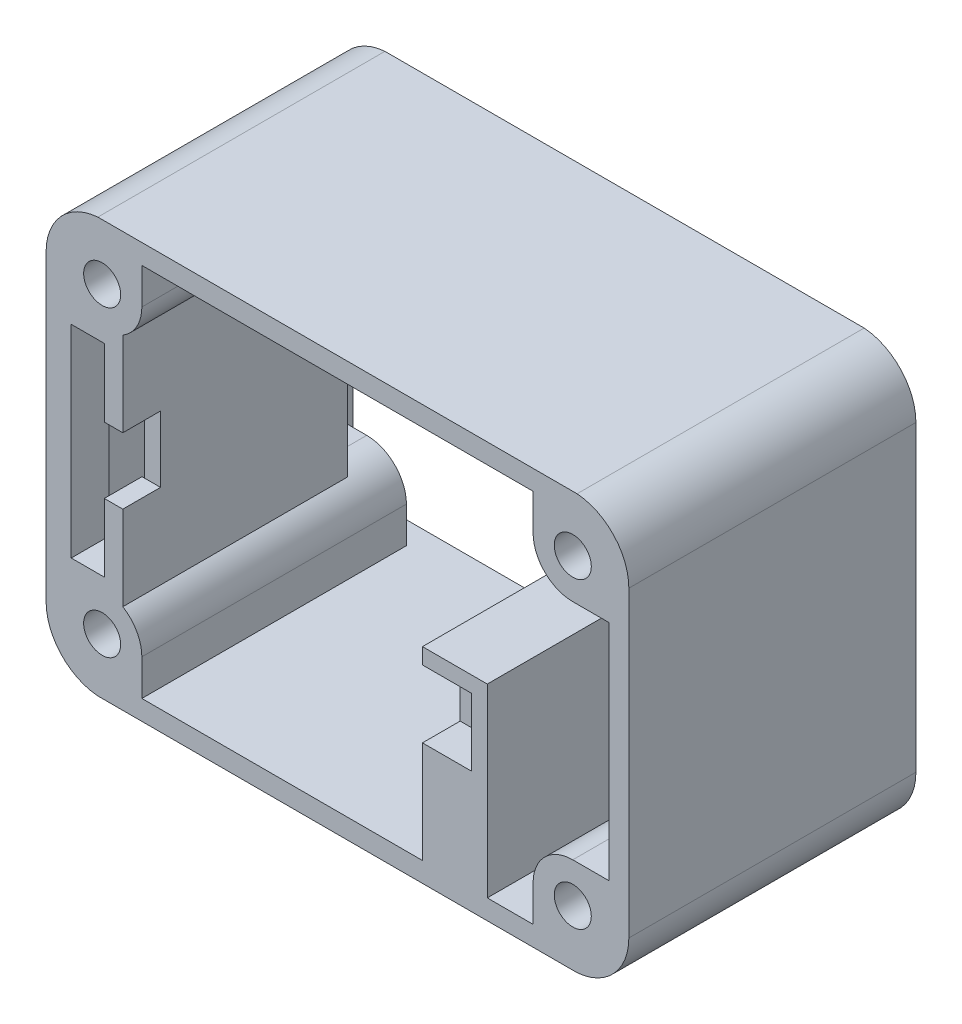
from build123d import *

# Parameters (mm, degrees)
SKETCH1_W           = 44.05
SKETCH1_H           = 31.35
SKETCH1_R           = 1.4
BOSS_EXTRUDE1_DEPTH = 20
SKETCH2_W           = 44.05
SKETCH2_H           = 31.35
BOSS_EXTRUDE2_DEPTH = 1.7
SKETCH3_W           = 2.9
SKETCH3_H           = 15.7
SKETCH3_W_2         = 4.9
SKETCH3_H_2         = 14
SKETCH3_H_3         = 5.5
BOSS_EXTRUDE3_DEPTH = 14.15
SKETCH4_W           = 4.9
SKETCH4_H           = 14
SKETCH4_W_2         = 2.5
SKETCH4_H_2         = 5.1
SKETCH4_H_3         = 15.3
BOSS_EXTRUDE4_DEPTH = 2.85
SKETCH5_W           = 1.4
SKETCH5_H           = 5
SKETCH5_W_2         = 1.2
SKETCH5_H_2         = 5.1
CUT_EXTRUDE1_DEPTH  = 2.85
CUT_EXTRUDE2_REACH  = 23.7


with BuildPart() as part:
    # Sketch1 → Boss-Extrude1 (new body)
    with BuildSketch(Plane.XY):
        Rectangle(SKETCH1_W, SKETCH1_H)
        with Locations((-17.7875, -11.45)):
            Circle(SKETCH1_R, mode=Mode.SUBTRACT)
        with Locations((17.7875, -11.45)):
            Circle(SKETCH1_R, mode=Mode.SUBTRACT)
        with BuildLine():
            Line((-17.7875, -8.45), (-20.525, -8.45))
            Line((-20.525, -8.45), (-20.525, 8.45))
            Line((-20.525, 8.45), (-17.7875, 8.45))
            ThreePointArc((-17.7875, 8.45), (-15.666179656, 9.328679656), (-14.7875, 11.45))
            Line((-14.7875, 11.45), (-14.7875, 14.175))
            Line((-14.7875, 14.175), (14.7875, 14.175))
            Line((14.7875, 14.175), (14.7875, 11.45))
            ThreePointArc((14.7875, 11.45), (15.666179656, 9.328679656), (17.7875, 8.45))
            Line((17.7875, 8.45), (20.525, 8.45))
            Line((20.525, 8.45), (20.525, -8.45))
            Line((20.525, -8.45), (17.7875, -8.45))
            ThreePointArc((17.7875, -8.45), (15.666179656, -9.328679656), (14.7875, -11.45))
            Line((14.7875, -11.45), (14.7875, -14.175))
            Line((14.7875, -14.175), (-14.7875, -14.175))
            Line((-14.7875, -14.175), (-14.7875, -11.45))
            ThreePointArc((-14.7875, -11.45), (-15.666179656, -9.328679656), (-17.7875, -8.45))
        make_face(mode=Mode.SUBTRACT)
        with Locations((-17.7875, 11.45)):
            Circle(SKETCH1_R, mode=Mode.SUBTRACT)
        with Locations((17.7875, 11.45)):
            Circle(SKETCH1_R, mode=Mode.SUBTRACT)
    extrude(amount=BOSS_EXTRUDE1_DEPTH)

    # Sketch2 → Boss-Extrude2 (add)
    with BuildSketch(Plane(origin=(0, 0, 0), x_dir=(-1, 0, 0), z_dir=(0, 0, -1))):
        Rectangle(SKETCH2_W, SKETCH2_H)
        Polygon((-20.525, 8.45), (-20.525, 14.175), (-14.7875, 14.175), (-2, 14.175), (-2, 14.925), (2, 14.925), (2, 14.175), (14.7875, 14.175), (20.525, 14.175), (20.525, 8.45), (20.525, 2), (21.275, 2), (21.275, -2), (20.525, -2), (20.525, -8.45), (20.525, -14.175), (14.7875, -14.175), (2, -14.175), (2, -14.925), (-2, -14.925), (-2, -14.175), (-14.7875, -14.175), (-20.525, -14.175), (-20.525, -8.45), (-20.525, -2), (-21.275, -2), (-21.275, 2), (-20.525, 2), align=None, mode=Mode.SUBTRACT)
    extrude(amount=BOSS_EXTRUDE2_DEPTH)

    # Sketch3 → Boss-Extrude3 (add)
    with BuildSketch(Plane(origin=(0, 0, 3), x_dir=(-1, 0, 0), z_dir=(0, 0, -1))):
        with BuildLine():
            ThreePointArc((16.225, -8.889024844), (16.975996909, -8.561840944), (17.7875, -8.45))
            Line((17.7875, -8.45), (20.525, -8.45))
            Line((20.525, -8.45), (20.525, 8.45))
            Line((20.525, 8.45), (17.7875, 8.45))
            ThreePointArc((17.7875, 8.45), (16.975996909, 8.561840944), (16.225, 8.889024844))
            Line((16.225, 8.889024844), (16.225, -8.889024844))
        make_face()
        with Locations((18.875, 0)):
            Rectangle(SKETCH3_W, SKETCH3_H, mode=Mode.SUBTRACT)
        with Locations((-8.875, -7.175)):
            Rectangle(SKETCH3_W_2, SKETCH3_H_2)
        with Locations((-8.875, -3.925)):
            Rectangle(SKETCH3_W, SKETCH3_H_3, mode=Mode.SUBTRACT)
    extrude(amount=-BOSS_EXTRUDE3_DEPTH)

    # Sketch4 → Boss-Extrude4 (add)
    with BuildSketch(Plane.XY.offset(17.15)):
        with Locations((8.875, -7.175)):
            Rectangle(SKETCH4_W, SKETCH4_H)
        with Locations((8.875, -3.925)):
            Rectangle(SKETCH4_W_2, SKETCH4_H_2, mode=Mode.SUBTRACT)
        with BuildLine():
            Line((-20.525, -8.45), (-17.7875, -8.45))
            ThreePointArc((-17.7875, -8.45), (-16.975996909, -8.561840944), (-16.225, -8.889024844))
            Line((-16.225, -8.889024844), (-16.225, 8.889024844))
            ThreePointArc((-16.225, 8.889024844), (-16.975996909, 8.561840944), (-17.7875, 8.45))
            Line((-17.7875, 8.45), (-20.525, 8.45))
            Line((-20.525, 8.45), (-20.525, -8.45))
        make_face()
        with Locations((-18.875, 0)):
            Rectangle(SKETCH4_W_2, SKETCH4_H_3, mode=Mode.SUBTRACT)
    extrude(amount=BOSS_EXTRUDE4_DEPTH)

    # Sketch5 → Cut-Extrude1 (cut)
    with BuildSketch(Plane.XY.offset(20)):
        with Locations((-16.925, 0)):
            Rectangle(SKETCH5_W, SKETCH5_H)
        with Locations((7.025, -3.925)):
            Rectangle(SKETCH5_W_2, SKETCH5_H_2)
    extrude(amount=-CUT_EXTRUDE1_DEPTH, mode=Mode.SUBTRACT)

    # Sketch6 → Cut-Extrude2 (cut, up to next)
    with BuildSketch(Plane(origin=(0, 0, -1.7), x_dir=(-1, 0, 0), z_dir=(0, 0, -1)), mode=Mode.PRIVATE) as cut_extrude2_sk1:
        with BuildLine():
            Line((-18.112740296, 15.675), (-22.025, 15.675))
            Line((-22.025, 15.675), (-22.025, 11.45))
            ThreePointArc((-22.025, 11.45), (-20.896729165, 14.329079757), (-18.112740296, 15.675))
        make_face()
    cut_extrude2_tool1 = extrude(cut_extrude2_sk1.sketch, amount=-CUT_EXTRUDE2_REACH, mode=Mode.PRIVATE) & part.part
    add(cut_extrude2_tool1.solids().sort_by_distance((21.092545, 14.728552, -1.7))[0], mode=Mode.SUBTRACT)
    # Sketch6 → Cut-Extrude2 (cut, up to next)
    with BuildSketch(Plane(origin=(0, 0, -1.7), x_dir=(-1, 0, 0), z_dir=(0, 0, -1)), mode=Mode.PRIVATE) as cut_extrude2_sk2:
        with BuildLine():
            Line((22.025, 15.675), (18.112740296, 15.675))
            ThreePointArc((18.112740296, 15.675), (20.896729165, 14.329079757), (22.025, 11.45))
            Line((22.025, 11.45), (22.025, 15.675))
        make_face()
    cut_extrude2_tool2 = extrude(cut_extrude2_sk2.sketch, amount=-CUT_EXTRUDE2_REACH, mode=Mode.PRIVATE) & part.part
    add(cut_extrude2_tool2.solids().sort_by_distance((-21.092545, 14.728552, -1.7))[0], mode=Mode.SUBTRACT)
    # Sketch6 → Cut-Extrude2 (cut, up to next)
    with BuildSketch(Plane(origin=(0, 0, -1.7), x_dir=(-1, 0, 0), z_dir=(0, 0, -1)), mode=Mode.PRIVATE) as cut_extrude2_sk3:
        with BuildLine():
            Line((22.025, -15.675), (22.025, -11.45))
            ThreePointArc((22.025, -11.45), (20.896729165, -14.329079757), (18.112740296, -15.675))
            Line((18.112740296, -15.675), (22.025, -15.675))
        make_face()
    cut_extrude2_tool3 = extrude(cut_extrude2_sk3.sketch, amount=-CUT_EXTRUDE2_REACH, mode=Mode.PRIVATE) & part.part
    add(cut_extrude2_tool3.solids().sort_by_distance((-21.092545, -14.728552, -1.7))[0], mode=Mode.SUBTRACT)
    # Sketch6 → Cut-Extrude2 (cut, up to next)
    with BuildSketch(Plane(origin=(0, 0, -1.7), x_dir=(-1, 0, 0), z_dir=(0, 0, -1)), mode=Mode.PRIVATE) as cut_extrude2_sk4:
        with BuildLine():
            ThreePointArc((-18.112740296, -15.675), (-20.896729167, -14.329079755), (-22.025, -11.449999993))
            Line((-22.025, -11.449999993), (-22.025, -15.675))
            Line((-22.025, -15.675), (-18.112740296, -15.675))
        make_face()
    cut_extrude2_tool4 = extrude(cut_extrude2_sk4.sketch, amount=-CUT_EXTRUDE2_REACH, mode=Mode.PRIVATE) & part.part
    add(cut_extrude2_tool4.solids().sort_by_distance((21.092545, -14.728552, -1.7))[0], mode=Mode.SUBTRACT)


solid = part.part
